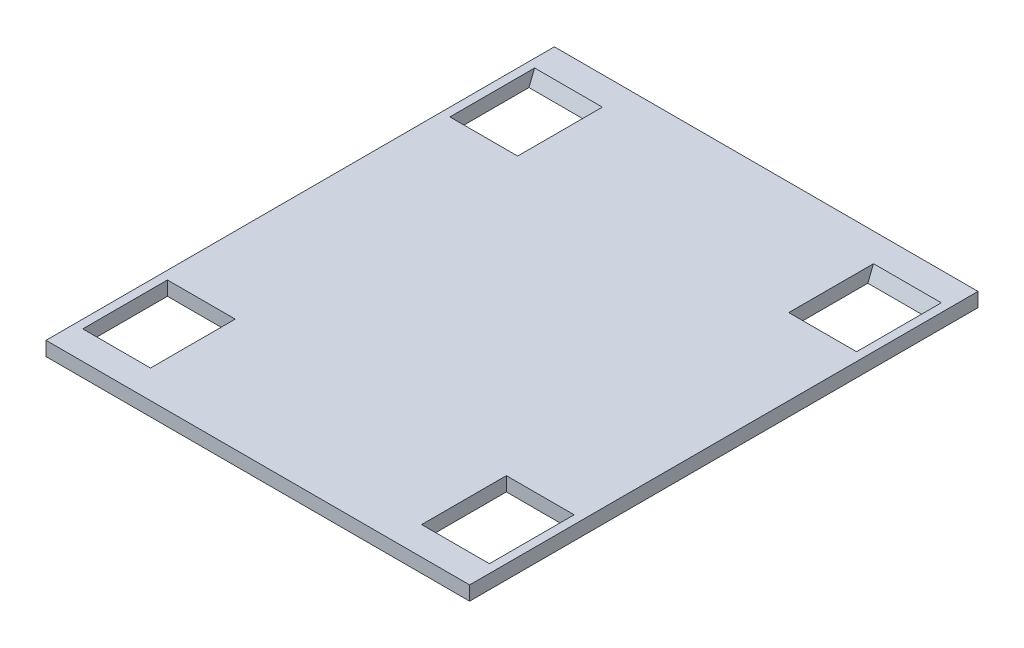
from build123d import *

# Parameters (mm, degrees)
SKETCH1_W            = 190.5
SKETCH1_H            = 228.6
BOSS_EXTRUDE1_DEPTH  = 6.35
CUT_EXTRUDE1_REACH   = 8.35
SKETCH2_W            = 30.48
SKETCH2_H            = 38.1
BOSS_EXTRUDE2_DEPTH  = 30.48
MIRROR2_COPY_1_DEPTH = 30.48


with BuildPart() as part:
    # Sketch1 → Boss-Extrude1 (new body)
    with BuildSketch(Plane(origin=(0, 0, 0), x_dir=(1, 0, 0), z_dir=(0, 1, 0))):
        Rectangle(SKETCH1_W, SKETCH1_H)
    extrude(amount=BOSS_EXTRUDE1_DEPTH)

    # Sketch2 → Cut-Extrude1 (cut, up to next)
    with BuildSketch(Plane(origin=(0, 6.35, 0), x_dir=(1, 0, 0), z_dir=(0, 1, 0)), mode=Mode.PRIVATE) as cut_extrude1_sk1:
        with Locations((-76.2, 82.55)):
            Rectangle(SKETCH2_W, SKETCH2_H)
    cut_extrude1_tool1 = extrude(cut_extrude1_sk1.sketch, amount=-CUT_EXTRUDE1_REACH, mode=Mode.PRIVATE) & part.part
    add(cut_extrude1_tool1.solids().sort_by_distance((-76.2, 6.35, -82.55))[0], mode=Mode.SUBTRACT)
    # Sketch2 → Cut-Extrude1 (cut, up to next)
    with BuildSketch(Plane(origin=(0, 6.35, 0), x_dir=(1, 0, 0), z_dir=(0, 1, 0)), mode=Mode.PRIVATE) as cut_extrude1_sk2:
        with Locations((-76.2, -82.55)):
            Rectangle(SKETCH2_W, SKETCH2_H)
    cut_extrude1_tool2 = extrude(cut_extrude1_sk2.sketch, amount=-CUT_EXTRUDE1_REACH, mode=Mode.PRIVATE) & part.part
    add(cut_extrude1_tool2.solids().sort_by_distance((-76.2, 6.35, 82.55))[0], mode=Mode.SUBTRACT)
    # Sketch2 → Cut-Extrude1 (cut, up to next)
    with BuildSketch(Plane(origin=(0, 6.35, 0), x_dir=(1, 0, 0), z_dir=(0, 1, 0)), mode=Mode.PRIVATE) as cut_extrude1_sk3:
        with Locations((76.2, -82.55)):
            Rectangle(SKETCH2_W, SKETCH2_H)
    cut_extrude1_tool3 = extrude(cut_extrude1_sk3.sketch, amount=-CUT_EXTRUDE1_REACH, mode=Mode.PRIVATE) & part.part
    add(cut_extrude1_tool3.solids().sort_by_distance((76.2, 6.35, 82.55))[0], mode=Mode.SUBTRACT)
    # Sketch2 → Cut-Extrude1 (cut, up to next)
    with BuildSketch(Plane(origin=(0, 6.35, 0), x_dir=(1, 0, 0), z_dir=(0, 1, 0)), mode=Mode.PRIVATE) as cut_extrude1_sk4:
        with Locations((76.2, 82.55)):
            Rectangle(SKETCH2_W, SKETCH2_H)
    cut_extrude1_tool4 = extrude(cut_extrude1_sk4.sketch, amount=-CUT_EXTRUDE1_REACH, mode=Mode.PRIVATE) & part.part
    add(cut_extrude1_tool4.solids().sort_by_distance((76.2, 6.35, -82.55))[0], mode=Mode.SUBTRACT)

    # Sketch3 → Boss-Extrude2 (add)
    with BuildSketch(Plane.ZY.offset(-91.44)):
        Polygon((-101.6, 6.35), (-101.6, 0), (-99.06, 0), align=None)
    boss_extrude2 = extrude(amount=BOSS_EXTRUDE2_DEPTH)

    # Mirror1: Boss-Extrude2 across plane
    add(boss_extrude2.mirror(Plane.XY))

    # Mirror2: Boss-Extrude2 across plane
    add(boss_extrude2.mirror(Plane(origin=(0, 0, 0), x_dir=(0, 0, 1), z_dir=(1, 0, 0))))

    # Mirror2 copy 1 sketch → Mirror2 copy 1 (add)
    with BuildSketch(Plane(origin=(-91.44, 0, 0), x_dir=(0, 0, -1), z_dir=(1, 0, 0))):
        Polygon((-101.6, 6.35), (-101.6, 0), (-99.06, 0), align=None)
    extrude(amount=MIRROR2_COPY_1_DEPTH)


solid = part.part
